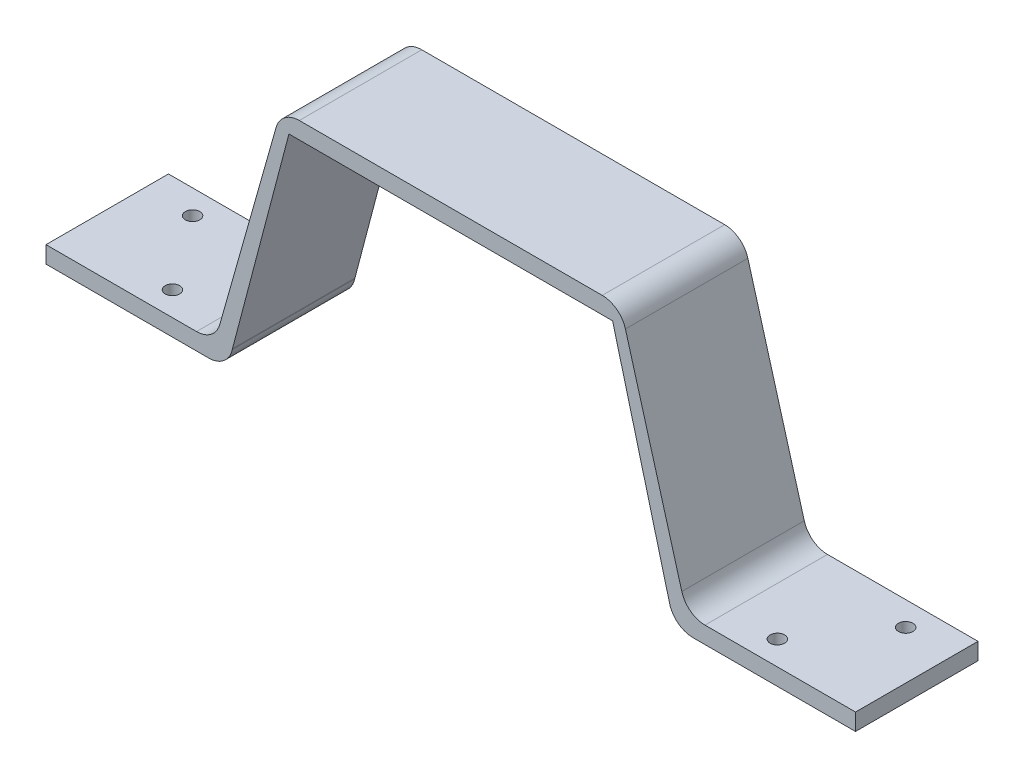
from build123d import *

# Parameters (mm, degrees)
CROQUIS1_W              = 167.894
CROQUIS1_H              = 52.07
SALIENTE_EXTRUIR1_DEPTH = 25.4
CROQUIS2_W              = 35
CROQUIS2_H              = 48.57
CORTAR_EXTRUIR1_DEPTH   = 25.4
CORTAR_EXTRUIR2_DEPTH   = 25.4
REDONDEO1_R             = 5
REDONDEO2_R             = 5
REDONDEO6_R             = 5
REDONDEO7_R             = 5
REDONDEO11_R            = 5
REDONDEO12_R            = 5
REDONDEO13_R            = 5
CROQUIS4_R              = 1.5
CORTAR_EXTRUIR3_DEPTH   = 76.2


with BuildPart() as part:
    # Croquis1 → Saliente-Extruir1 (new body)
    with BuildSketch(Plane.XY):
        with Locations((-83.947, 26.035)):
            Rectangle(CROQUIS1_W, CROQUIS1_H)
    extrude(amount=SALIENTE_EXTRUIR1_DEPTH)

    # Croquis2 → Cortar-Extruir1 (cut)
    with BuildSketch(Plane.XY.offset(25.4)):
        Polygon((-119.137953593, 52.07), (-132.894, 52.07), (-132.894, 3.5), (-120.129227268, 48.57), align=None)
        with Locations((-150.394, 27.785)):
            Rectangle(CROQUIS2_W, CROQUIS2_H)
        with Locations((-17.5, 27.785)):
            Rectangle(CROQUIS2_W, CROQUIS2_H)
        Polygon((-35, 52.07), (-48.756046407, 52.07), (-47.764772732, 48.57), (-35, 3.5), align=None)
    extrude(amount=-CORTAR_EXTRUIR1_DEPTH, mode=Mode.SUBTRACT)

    # Croquis3 → Cortar-Extruir2 (cut)
    with BuildSketch(Plane.XY.offset(25.4)):
        Polygon((-117.509109836, 48.57), (-50.384890164, 48.57), (-38.5, 3.5), (-38.5, 0), (-129.394, 0), (-129.394, 3.5), align=None)
    extrude(amount=-CORTAR_EXTRUIR2_DEPTH, mode=Mode.SUBTRACT)

    # Redondeo1
    redondeo1_edges = [part.edges().sort_by_distance(p)[0] for p in [
        (-48.756046407, 52.07, 12.7),
    ]]
    fillet(redondeo1_edges, radius=REDONDEO1_R)

    # Redondeo2
    redondeo2_edges = [part.edges().sort_by_distance(p)[0] for p in [
        (-119.137953593, 52.07, 12.7),
    ]]
    fillet(redondeo2_edges, radius=REDONDEO2_R)

    # Redondeo6
    redondeo6_edges = [part.edges().sort_by_distance(p)[0] for p in [
        (-38.5, 3.5, 12.7),
    ]]
    fillet(redondeo6_edges, radius=REDONDEO6_R)

    # Redondeo7
    redondeo7_edges = [part.edges().sort_by_distance(p)[0] for p in [
        (-129.394, 3.5, 12.7),
    ]]
    fillet(redondeo7_edges, radius=REDONDEO7_R)

    # Redondeo11
    redondeo11_edges = [part.edges().sort_by_distance(p)[0] for p in [
        (-129.394, 0, 12.7),
    ]]
    fillet(redondeo11_edges, radius=REDONDEO11_R)

    # Redondeo12
    redondeo12_edges = [part.edges().sort_by_distance(p)[0] for p in [
        (-38.5, 0, 12.7),
    ]]
    fillet(redondeo12_edges, radius=REDONDEO12_R)

    # Redondeo13
    redondeo13_edges = [part.edges().sort_by_distance(p)[0] for p in [
        (-132.894, 3.5, 12.7),
        (-35, 3.5, 12.7),
    ]]
    fillet(redondeo13_edges, radius=REDONDEO13_R)

    # Croquis4 → Cortar-Extruir3 (cut)
    with BuildSketch(Plane(origin=(0, 52.07, 0), x_dir=(1, 0, 0), z_dir=(0, 1, 0))):
        with Locations((-157.894, -5)):
            Circle(CROQUIS4_R)
        with Locations((-146.674562343, -20.4)):
            Circle(CROQUIS4_R)
        with Locations((-21.219437657, -20.4)):
            Circle(CROQUIS4_R)
        with Locations((-10, -5)):
            Circle(CROQUIS4_R)
    extrude(amount=-CORTAR_EXTRUIR3_DEPTH, mode=Mode.SUBTRACT)


solid = part.part
